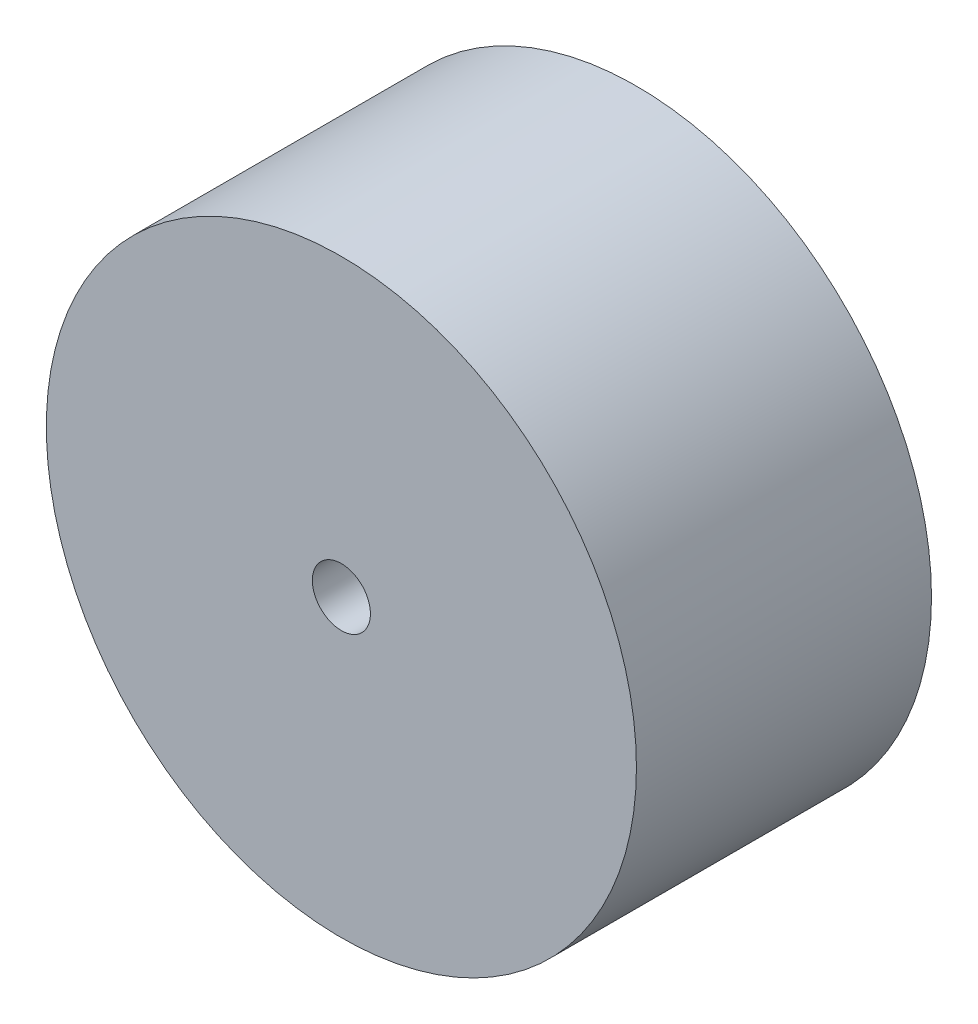
from build123d import *

# Parameters (mm, degrees)
SKETCH2_R           = 25.4
SKETCH2_R_2         = 2.5
BOSS_EXTRUDE1_DEPTH = 25.4


with BuildPart() as part:
    # Sketch2 → Boss-Extrude1 (new body)
    with BuildSketch(Plane.XY):
        Circle(SKETCH2_R)
        Circle(SKETCH2_R_2, mode=Mode.SUBTRACT)
    extrude(amount=BOSS_EXTRUDE1_DEPTH)


solid = part.part
